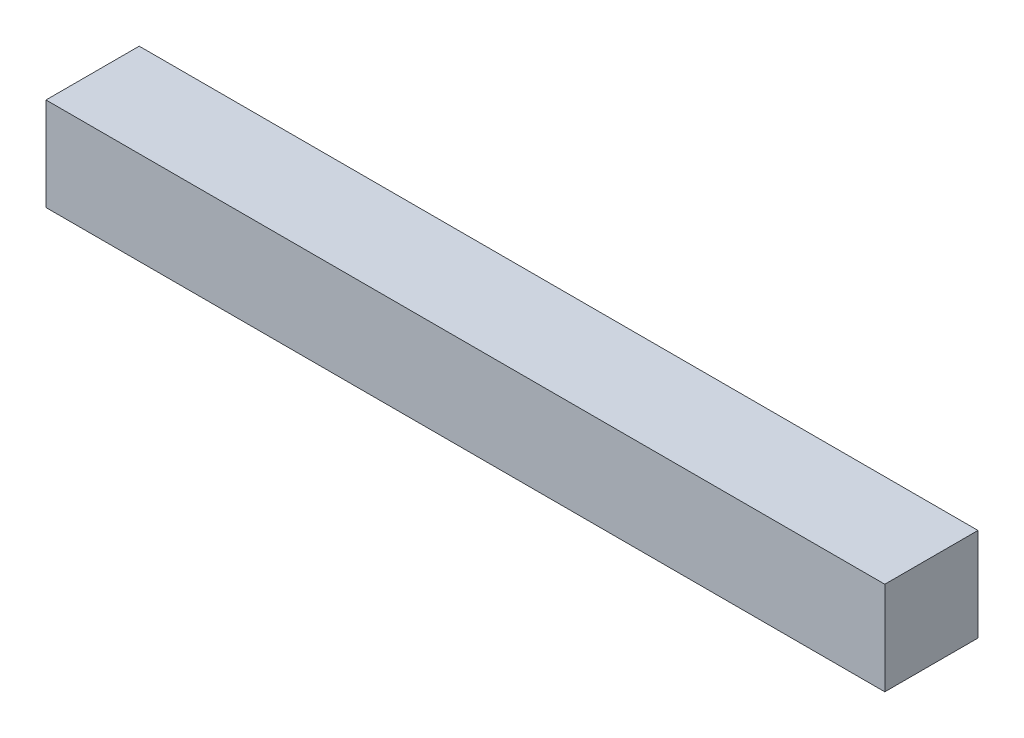
from build123d import *

# Parameters (mm, degrees)
SKETCH1_W           = 228.6
SKETCH1_H           = 25.4
BOSS_EXTRUDE2_DEPTH = 25.4


with BuildPart() as part:
    # Sketch1 → Boss-Extrude2 (new body)
    with BuildSketch(Plane(origin=(0, 0, 0), x_dir=(1, 0, 0), z_dir=(0, 1, 0))):
        Rectangle(SKETCH1_W, SKETCH1_H)
    extrude(amount=BOSS_EXTRUDE2_DEPTH)


solid = part.part
